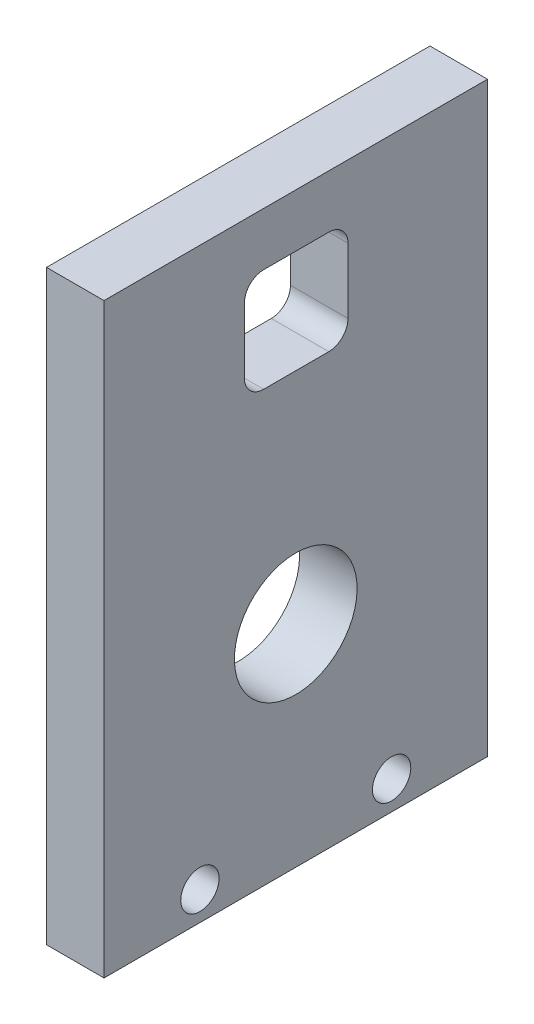
from build123d import *

# Parameters (mm, degrees)
IZIM1_W                     = 15
IZIM1_H                     = 153
Y_KSEKLIK_EKSTR_ZYON1_DEPTH = 100
IZIM2_R                     = 5
KES_EKSTR_ZYON2_DEPTH       = 16
IZIM3_R                     = 16
KES_EKSTR_ZYON3_DEPTH       = 16


with BuildPart() as part:
    # Çizim1 → Yükseklik-Ekstrüzyon1 (new body)
    with BuildSketch(Plane.XY):
        Rectangle(IZIM1_W, IZIM1_H)
    extrude(amount=Y_KSEKLIK_EKSTR_ZYON1_DEPTH)

    # Çizim2 → Kes-Ekstrüzyon2 (cut, through all)
    with BuildSketch(Plane(origin=(7.5, 0, 0), x_dir=(0, 0, -1), z_dir=(1, 0, 0))):
        with Locations((-75, -69)):
            Circle(IZIM2_R)
        with Locations((-25, -69)):
            Circle(IZIM2_R)
    extrude(amount=-KES_EKSTR_ZYON2_DEPTH, mode=Mode.SUBTRACT)

    # Çizim3 → Kes-Ekstrüzyon3 (cut, through all)
    with BuildSketch(Plane(origin=(7.5, 0, 0), x_dir=(0, 0, -1), z_dir=(1, 0, 0))):
        with Locations((-50, -21.5)):
            Circle(IZIM3_R)
        with BuildLine():
            Line((-58.38409441, 35.653702621), (-41.38409441, 35.653702621))
            ThreePointArc((-41.38409441, 35.653702621), (-37.848560504, 37.118168715), (-36.38409441, 40.653702621))
            Line((-36.38409441, 40.653702621), (-36.38409441, 57.653702621))
            ThreePointArc((-36.38409441, 57.653702621), (-37.848560504, 61.189236527), (-41.38409441, 62.653702621))
            Line((-41.38409441, 62.653702621), (-58.38409441, 62.653702621))
            ThreePointArc((-58.38409441, 62.653702621), (-61.919628316, 61.189236527), (-63.38409441, 57.653702621))
            Line((-63.38409441, 57.653702621), (-63.38409441, 40.653702621))
            ThreePointArc((-63.38409441, 40.653702621), (-61.919628316, 37.118168715), (-58.38409441, 35.653702621))
        make_face()
    extrude(amount=-KES_EKSTR_ZYON3_DEPTH, mode=Mode.SUBTRACT)


solid = part.part
